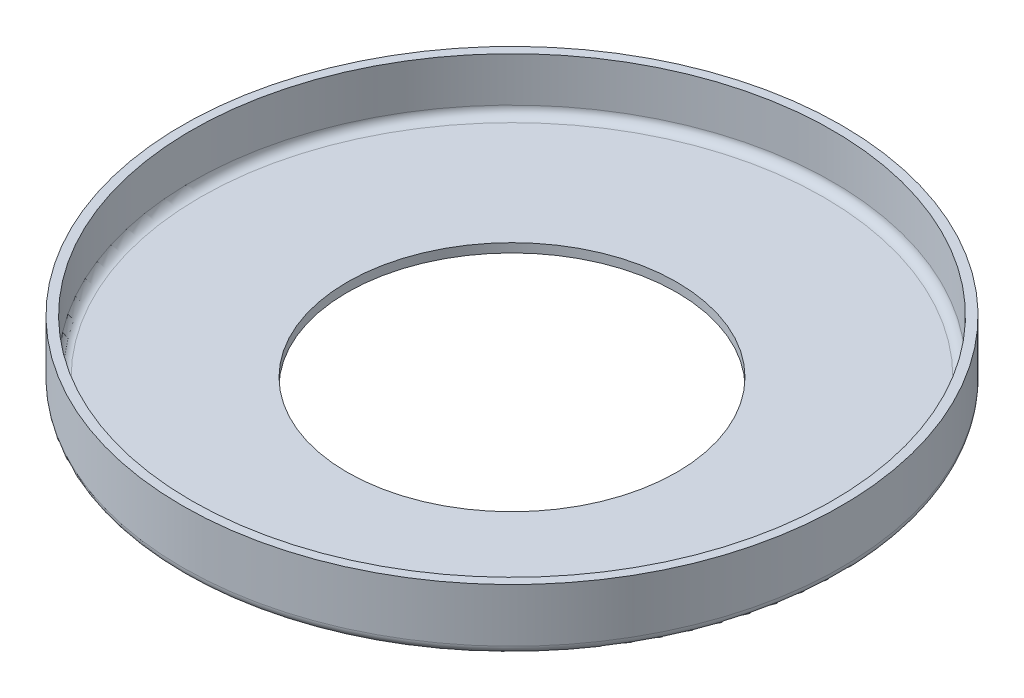
from build123d import *

# Parameters (mm, degrees)
SKETCH1_R           = 37
BOSS_EXTRUDE1_DEPTH = 7
SKETCH2_R           = 36
CUT_EXTRUDE1_DEPTH  = 6
SKETCH3_R           = 18.5
CUT_EXTRUDE2_DEPTH  = 6
FILLET1_R           = 1


with BuildPart() as part:
    # Sketch1 → Boss-Extrude1 (new body)
    with BuildSketch(Plane(origin=(0, 0, 0), x_dir=(1, 0, 0), z_dir=(0, 1, 0))):
        Circle(SKETCH1_R)
    extrude(amount=BOSS_EXTRUDE1_DEPTH)

    # Sketch2 → Cut-Extrude1 (cut)
    with BuildSketch(Plane(origin=(0, 7, 0), x_dir=(1, 0, 0), z_dir=(0, 1, 0))):
        Circle(SKETCH2_R)
    extrude(amount=-CUT_EXTRUDE1_DEPTH, mode=Mode.SUBTRACT)

    # Sketch3 → Cut-Extrude2 (cut)
    with BuildSketch(Plane(origin=(0, 1, 0), x_dir=(1, 0, 0), z_dir=(0, 1, 0))):
        Circle(SKETCH3_R)
    extrude(amount=-CUT_EXTRUDE2_DEPTH, mode=Mode.SUBTRACT)

    # Fillet1
    fillet1_edges = [part.edges().sort_by_distance(p)[0] for p in [
        (-37, 0, 0),
        (-36, 1, 0),
    ]]
    fillet(fillet1_edges, radius=FILLET1_R)


solid = part.part
